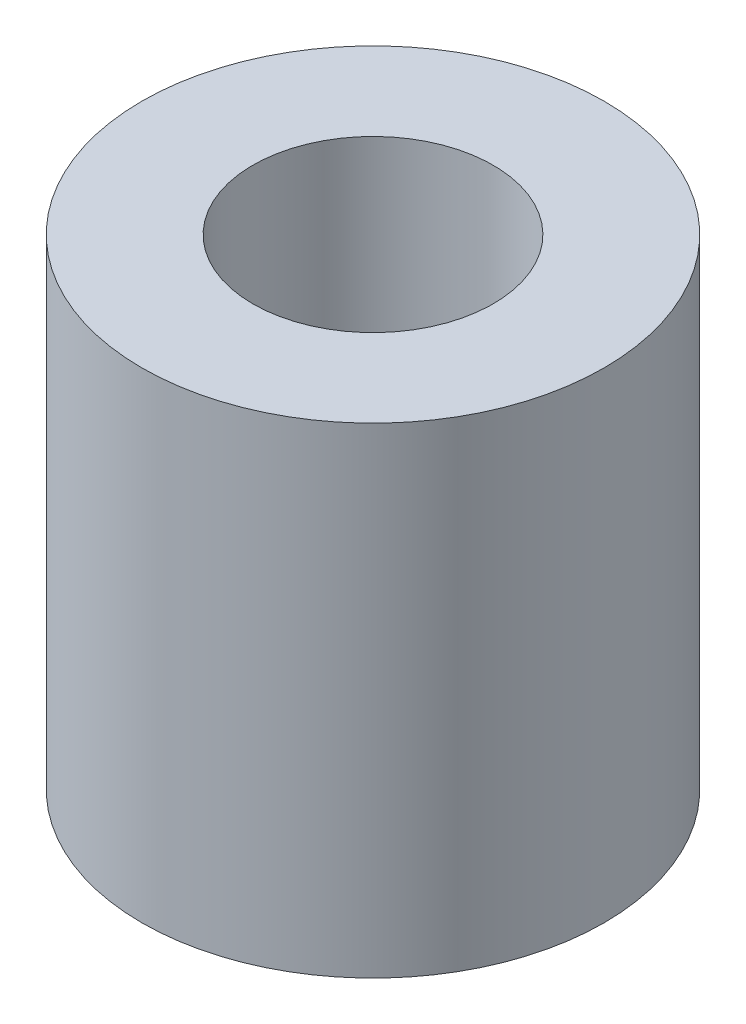
from build123d import *

# Parameters (mm, degrees)
ESQUISSE1_R      = 12.5
ESQUISSE1_R_2    = 6.5
EXTRUSION1_DEPTH = 26


with BuildPart() as part:
    # Esquisse1 → Extrusion1 (new body)
    with BuildSketch(Plane(origin=(0, 0, 0), x_dir=(1, 0, 0), z_dir=(0, 1, 0))):
        Circle(ESQUISSE1_R)
        Circle(ESQUISSE1_R_2, mode=Mode.SUBTRACT)
    extrude(amount=EXTRUSION1_DEPTH)


solid = part.part
